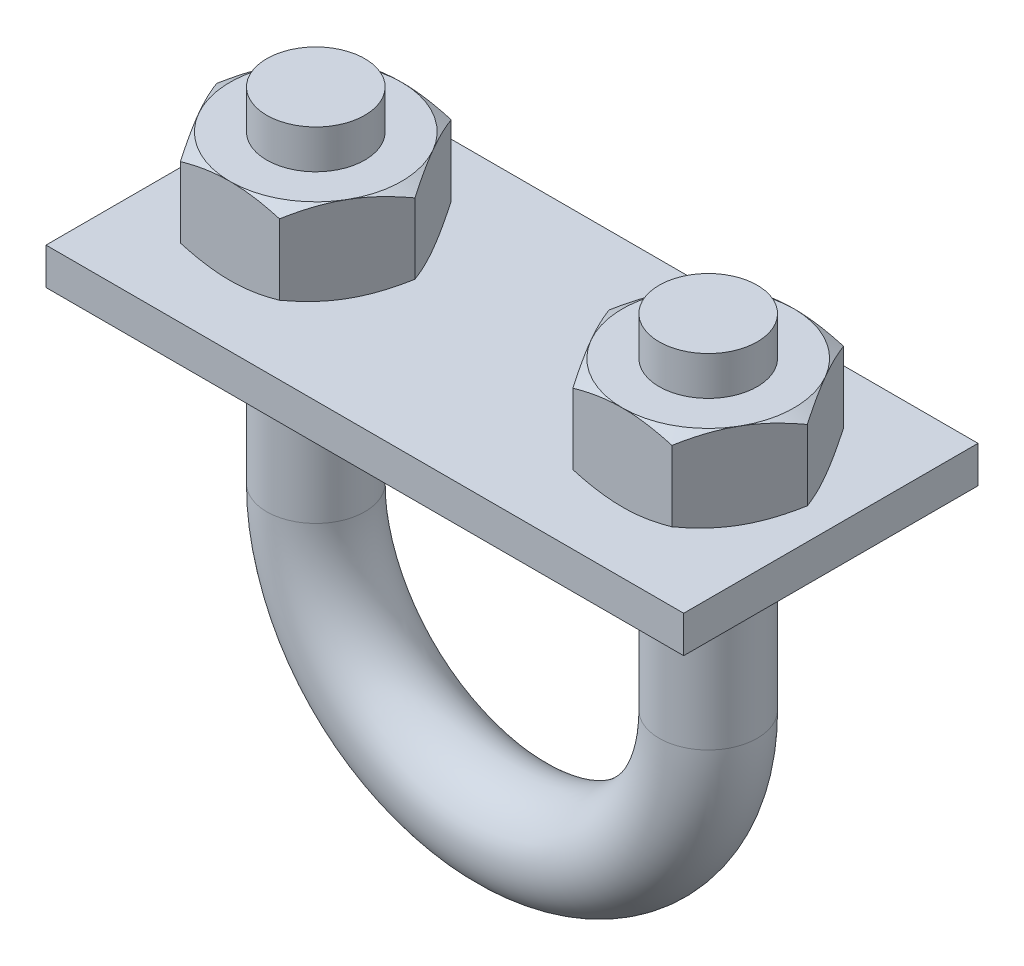
from build123d import *

# Parameters (mm, degrees)
SKETCH2_R           = 3.175
BOSS_EXTRUDE1_DEPTH = 15.875
SKETCH7_R           = 3.175
SKETCH9_R           = 3.175
BOSS_EXTRUDE2_DEPTH = 2.778125
SKETCH10_OUTSIDE_W  = 174.313
SKETCH10_OUTSIDE_H  = 150.434
SKETCH10_OUTSIDE_R  = 5.55625
CUT_EXTRUDE1_DEPTH  = 36.586458433
CUT_EXTRUDE1_TAPER  = 60
SKETCH11_OUTSIDE_W  = 78.991
SKETCH11_OUTSIDE_H  = 55.112
SKETCH11_OUTSIDE_R  = 5.55625
CUT_EXTRUDE2_DEPTH  = 9.069791667
CUT_EXTRUDE2_TAPER  = 60
SKETCH12_W          = 41.275
SKETCH12_H          = 19.05
BOSS_EXTRUDE3_DEPTH = 2.38125


with BuildPart() as part:
    # Sketch2 → Boss-Extrude1 (new body)
    with BuildSketch(Plane(origin=(0, 22.225, 0), x_dir=(-1, 0, 0), z_dir=(0, 1, 0))):
        with Locations((12.7, 0)):
            Circle(SKETCH2_R)
    extrude(amount=-BOSS_EXTRUDE1_DEPTH)


with BuildPart() as body_2:
    # Sweep1: sweep along a path in Sketch8
    with BuildLine(Plane.XY) as sweep1_path:
        Line((-12.7, 6.35), (-12.7, 0))
        ThreePointArc((-12.7, 0), (0, -12.7), (12.7, 0))
        Line((12.7, 0), (12.7, 6.35))
    # Sketch7 → Sweep1 (sweep)
    with BuildSketch(Plane(origin=(0, 6.35, 0), x_dir=(-1, 0, 0), z_dir=(0, 1, 0))):
        with Locations((12.7, 0)):
            Circle(SKETCH7_R)
    sweep(path=sweep1_path.line)


with BuildPart() as body_3:
    # Body-Move_Copy1: copy of part
    add(part.part.moved(Location((25.4, 0, 0))))


with BuildPart() as part_1:
    add(part.part)

    # Combine1: union body 2, body 3
    add(body_2.part)
    add(body_3.part)


with BuildPart() as body_2_2:
    # Sketch9 → Boss-Extrude2 (new body, symmetric)
    with BuildSketch(Plane(origin=(0, 16.933333333, 0), x_dir=(-1, 0, 0), z_dir=(0, 1, 0))):
        Polygon((-15.907902433, 5.55625), (-19.115804866, 0), (-15.907902433, -5.55625), (-9.492097567, -5.55625), (-6.284195134, 0), (-9.492097567, 5.55625), align=None)
        with Locations((-12.7, 0)):
            Circle(SKETCH9_R, mode=Mode.SUBTRACT)
    extrude(amount=BOSS_EXTRUDE2_DEPTH, both=True)

    # Sketch10 outside → Cut-Extrude1 (cut, through all)
    with BuildSketch(Plane(origin=(0, 19.711458333, 0), x_dir=(1, 0, 0), z_dir=(0, 1, 0))):
        with Locations((1.6205, 0)):
            Rectangle(SKETCH10_OUTSIDE_W, SKETCH10_OUTSIDE_H)
        with Locations((12.7, 0)):
            Circle(SKETCH10_OUTSIDE_R, mode=Mode.SUBTRACT)
    extrude(amount=-CUT_EXTRUDE1_DEPTH, taper=CUT_EXTRUDE1_TAPER, mode=Mode.SUBTRACT)

    # Sketch11 outside → Cut-Extrude2 (cut, through all)
    with BuildSketch(Plane.XZ.offset(-14.155208333)):
        with Locations((1.6205, 0)):
            Rectangle(SKETCH11_OUTSIDE_W, SKETCH11_OUTSIDE_H)
        with Locations((12.7, 0)):
            Circle(SKETCH11_OUTSIDE_R, mode=Mode.SUBTRACT)
    extrude(amount=-CUT_EXTRUDE2_DEPTH, taper=CUT_EXTRUDE2_TAPER, mode=Mode.SUBTRACT)


with BuildPart() as body_3_2:
    # Body-Move_Copy2: copy of body 2 2
    add(body_2_2.part.moved(Location((-25.4, 0, 0))))


with BuildPart() as body_4:
    # Sketch12 → Boss-Extrude3 (new body)
    with BuildSketch(Plane(origin=(0, 14.155208333, 0), x_dir=(1, 0, 0), z_dir=(0, 1, 0))):
        Rectangle(SKETCH12_W, SKETCH12_H)
    extrude(amount=-BOSS_EXTRUDE3_DEPTH)


solid = Compound([part_1.part, body_2_2.part, body_3_2.part, body_4.part])
